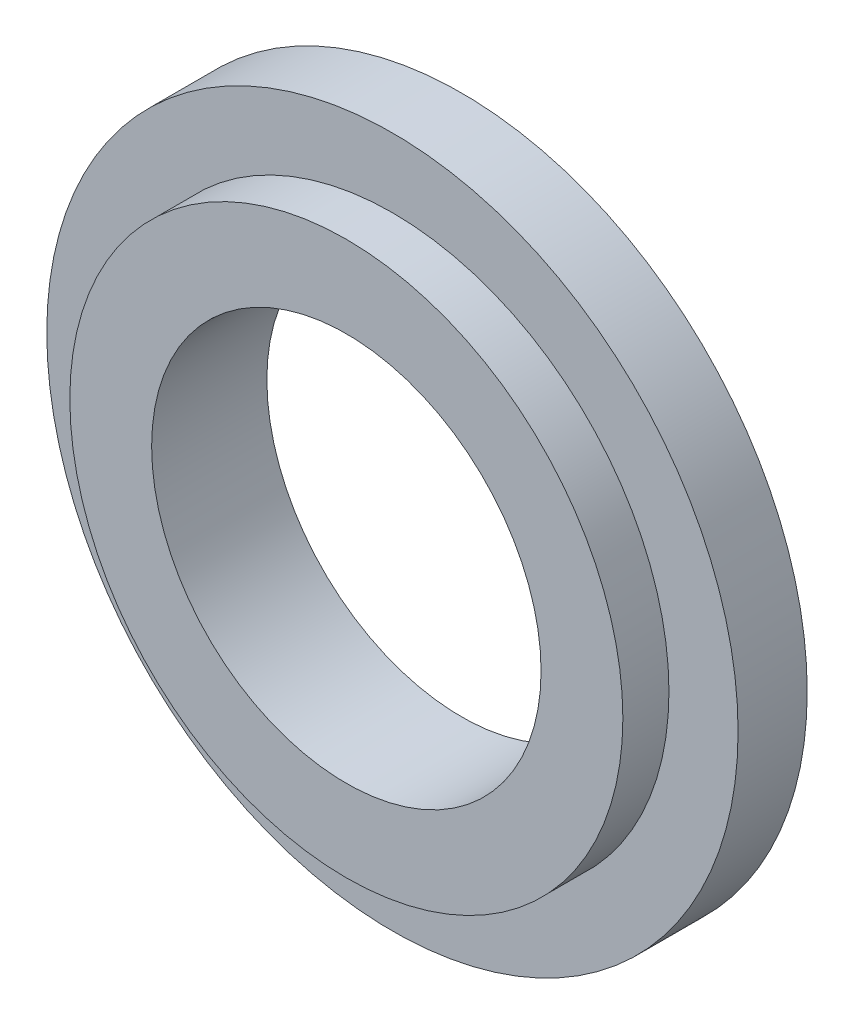
from build123d import *

# Parameters (mm, degrees)
SKETCH1_R      = 15
EXTRUDE1_DEPTH = 3
SKETCH2_R      = 12
EXTRUDE2_DEPTH = 2
SKETCH3_R      = 8.45
EXTRUDE3_DEPTH = 13


with BuildPart() as part:
    # Sketch1 → Extrude1 (new body)
    with BuildSketch(Plane.XY):
        Circle(SKETCH1_R)
    extrude(amount=EXTRUDE1_DEPTH)

    # Sketch2 → Extrude2 (add)
    with BuildSketch(Plane.XY.offset(3)):
        Circle(SKETCH2_R)
    extrude(amount=EXTRUDE2_DEPTH)

    # Sketch3 → Extrude3 (cut)
    with BuildSketch(Plane.XY.offset(5)):
        Circle(SKETCH3_R)
    extrude(amount=-EXTRUDE3_DEPTH, mode=Mode.SUBTRACT)


solid = part.part
